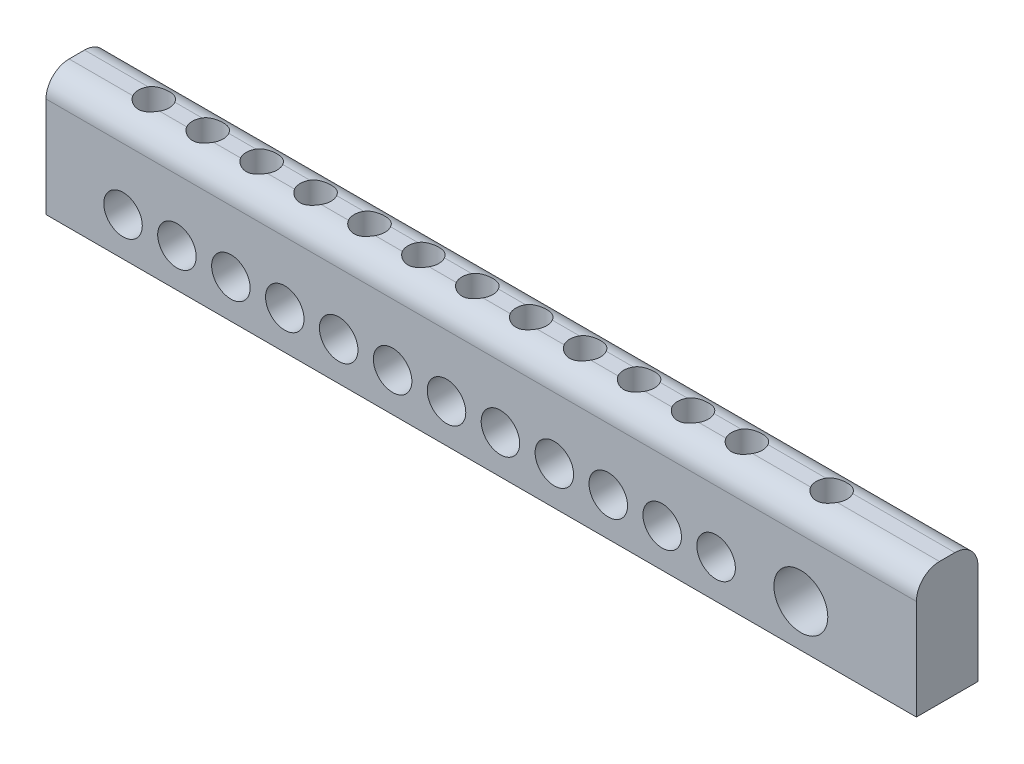
from build123d import *

# Parameters (mm, degrees)
ESQUISSE1_W                = 113
ESQUISSE1_H                = 16
EXTRUSION1_DEPTH           = 8
CONG_2_R                   = 3
ESQUISSE2_R                = 2.5
EXTRUSION2_DEPTH           = 7
R_P_TITION_LIN_AIRE1_COUNT = 12
R_P_TITION_LIN_AIRE1_PITCH = 7
ESQUISSE3_R                = 3.5
EXTRUSION3_DEPTH           = 7
ESQUISSE4_R                = 2
EXTRUSION4_DEPTH           = 10
R_P_TITION_LIN_AIRE2_COUNT = 12
R_P_TITION_LIN_AIRE2_PITCH = 7
ESQUISSE5_R                = 2
EXTRUSION5_DEPTH           = 10


with BuildPart() as part:
    # Esquisse1 → Extrusion1 (new body)
    with BuildSketch(Plane.XY):
        with Locations((56.5, -8)):
            Rectangle(ESQUISSE1_W, ESQUISSE1_H)
    extrude(amount=EXTRUSION1_DEPTH)

    # Congé2
    cong_2_edges = [part.edges().sort_by_distance(p)[0] for p in [
        (56.5, 0, 8),
        (56.5, 0, 0),
    ]]
    fillet(cong_2_edges, radius=CONG_2_R)

    # Esquisse2 → Extrusion2 (cut)
    with BuildSketch(Plane.XY.offset(8)):
        with Locations((10, -11)):
            Circle(ESQUISSE2_R)
    extrusion2 = extrude(amount=-EXTRUSION2_DEPTH, mode=Mode.SUBTRACT)

    # Répétition linéaire1: Extrusion2 ×12
    with Locations(*[(i * R_P_TITION_LIN_AIRE1_PITCH, 0, 0) for i in range(1, R_P_TITION_LIN_AIRE1_COUNT)]):
        add(extrusion2, mode=Mode.SUBTRACT)

    # Esquisse3 → Extrusion3 (cut)
    with BuildSketch(Plane.XY.offset(8)):
        with Locations((98, -10.5)):
            Circle(ESQUISSE3_R)
    extrude(amount=-EXTRUSION3_DEPTH, mode=Mode.SUBTRACT)

    # Esquisse4 → Extrusion4 (cut)
    with BuildSketch(Plane(origin=(0, 0, 0), x_dir=(1, 0, 0), z_dir=(0, 1, 0))):
        with Locations((10, -4)):
            Circle(ESQUISSE4_R)
    extrusion4 = extrude(amount=-EXTRUSION4_DEPTH, mode=Mode.SUBTRACT)

    # Répétition linéaire2: Extrusion4 ×12
    with Locations(*[(i * R_P_TITION_LIN_AIRE2_PITCH, 0, 0) for i in range(1, R_P_TITION_LIN_AIRE2_COUNT)]):
        add(extrusion4, mode=Mode.SUBTRACT)

    # Esquisse5 → Extrusion5 (cut)
    with BuildSketch(Plane(origin=(0, 0, 0), x_dir=(-1, 0, 0), z_dir=(0, 1, 0))):
        with Locations((-98, 4)):
            Circle(ESQUISSE5_R)
    extrude(amount=-EXTRUSION5_DEPTH, mode=Mode.SUBTRACT)


solid = part.part
